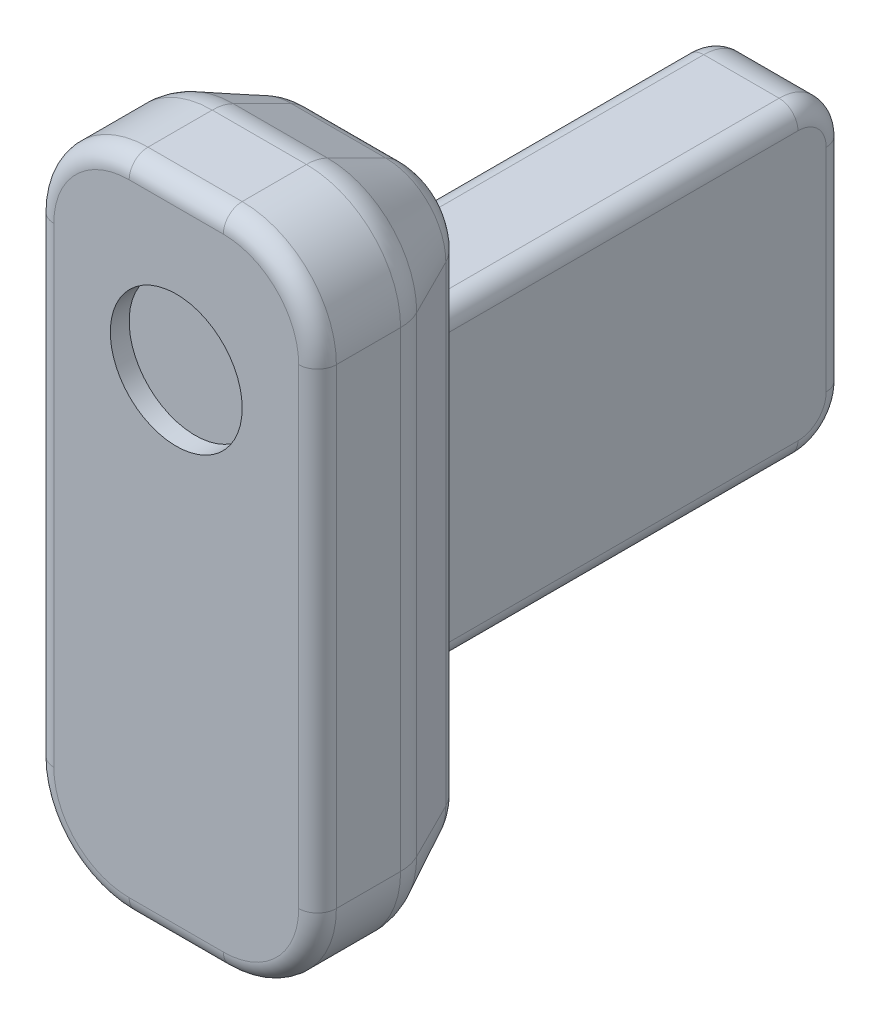
from build123d import *

# Parameters (mm, degrees)
SKETCH1_W           = 30
SKETCH1_H           = 70
BOSS_EXTRUDE1_DEPTH = 20
FILLET1_R           = 10
FILLET2_R           = 2
CHAMFER1_SIZE       = 5
CHAMFER1_SIZE2      = 10
FILLET3_R           = 5
SKETCH2_W           = 12
SKETCH2_H           = 32.5
BOSS_EXTRUDE2_DEPTH = 45
FILLET4_R           = 5
SKETCH3_R           = 7
CUT_EXTRUDE1_DEPTH  = 2
FILLET5_R           = 2


with BuildPart() as part:
    # Sketch1 → Boss-Extrude1 (new body)
    with BuildSketch(Plane.XY):
        with Locations((57.367254616, -81.313756287)):
            Rectangle(SKETCH1_W, SKETCH1_H)
    extrude(amount=-BOSS_EXTRUDE1_DEPTH)

    # Fillet1
    fillet1_edges = [part.edges().sort_by_distance(p)[0] for p in [
        (42.367254616, -46.313756287, -10),
        (72.367254616, -46.313756287, -10),
        (72.367254616, -116.313756287, -10),
        (42.367254616, -116.313756287, -10),
    ]]
    fillet(fillet1_edges, radius=FILLET1_R)

    # Fillet2
    fillet2_edges = [part.edges().sort_by_distance(p)[0] for p in [
        (57.367254616, -46.313756287, 0),
        (42.367254616, -81.313756287, 0),
        (57.367254616, -116.313756287, 0),
        (72.367254616, -81.313756287, 0),
        (69.438322428, -113.384824099, 0),
        (45.296186805, -113.384824099, 0),
        (69.438322428, -49.242688475, 0),
        (45.296186805, -49.242688475, 0),
    ]]
    fillet(fillet2_edges, radius=FILLET2_R)

    # Chamfer1
    chamfer1_edges = [part.edges().sort_by_distance(p)[0] for p in [
        (57.367254616, -46.313756287, -20),
        (42.367254616, -81.313756287, -20),
        (72.367254616, -81.313756287, -20),
        (57.367254616, -116.313756287, -20),
        (69.438322428, -113.384824099, -20),
        (45.296186805, -113.384824099, -20),
        (69.438322428, -49.242688475, -20),
        (45.296186805, -49.242688475, -20),
    ]]
    chamfer1_side = [part.faces().sort_by_distance(p)[0] for p in [
        (57.367254616, -81.313756287, -20),
    ]]
    chamfer(chamfer1_edges, length=CHAMFER1_SIZE, length2=CHAMFER1_SIZE2, reference=chamfer1_side[0])

    # Fillet3
    fillet3_edges = [part.edges().sort_by_distance(p)[0] for p in [
        (42.367254616, -81.313756287, -10),
        (67.367254616, -81.313756287, -20),
        (65.902788522, -52.778222381, -20),
        (65.902788522, -109.849290193, -20),
        (57.367254616, -51.313756287, -20),
        (57.367254616, -111.313756287, -20),
        (48.83172071, -52.778222381, -20),
        (48.83172071, -109.849290193, -20),
        (47.367254616, -81.313756287, -20),
        (45.296186805, -113.384824099, -10),
        (45.296186805, -49.242688475, -10),
        (57.367254616, -116.313756287, -10),
        (57.367254616, -46.313756287, -10),
        (69.438322428, -113.384824099, -10),
        (69.438322428, -49.242688475, -10),
        (72.367254616, -81.313756287, -10),
    ]]
    fillet(fillet3_edges, radius=FILLET3_R)

    # Sketch2 → Boss-Extrude2 (add)
    with BuildSketch(Plane(origin=(0, 0, -20), x_dir=(-1, 0, 0), z_dir=(0, 0, -1))):
        with Locations((-57.367254616, -82.563756287)):
            Rectangle(SKETCH2_W, SKETCH2_H)
    extrude(amount=BOSS_EXTRUDE2_DEPTH)

    # Fillet4
    fillet4_edges = [part.edges().sort_by_distance(p)[0] for p in [
        (57.367254616, -98.813756287, -65),
        (57.367254616, -66.313756287, -65),
    ]]
    fillet(fillet4_edges, radius=FILLET4_R)

    # Sketch3 → Cut-Extrude1 (cut)
    with BuildSketch(Plane.XY):
        with Locations((57.367254616, -63.313756287)):
            Circle(SKETCH3_R)
    extrude(amount=-CUT_EXTRUDE1_DEPTH, mode=Mode.SUBTRACT)

    # Fillet5
    fillet5_edges = [part.edges().sort_by_distance(p)[0] for p in [
        (63.367254616, -82.563756287, -65),
        (51.367254616, -82.563756287, -65),
        (63.367254616, -98.813756287, -40),
        (63.367254616, -66.313756287, -40),
        (63.367254616, -97.349290193, -63.535533906),
        (63.367254616, -67.778222381, -63.535533906),
        (51.367254616, -66.313756287, -40),
        (51.367254616, -98.813756287, -40),
        (51.367254616, -97.349290193, -63.535533906),
        (51.367254616, -67.778222381, -63.535533906),
    ]]
    fillet(fillet5_edges, radius=FILLET5_R)


solid = part.part
